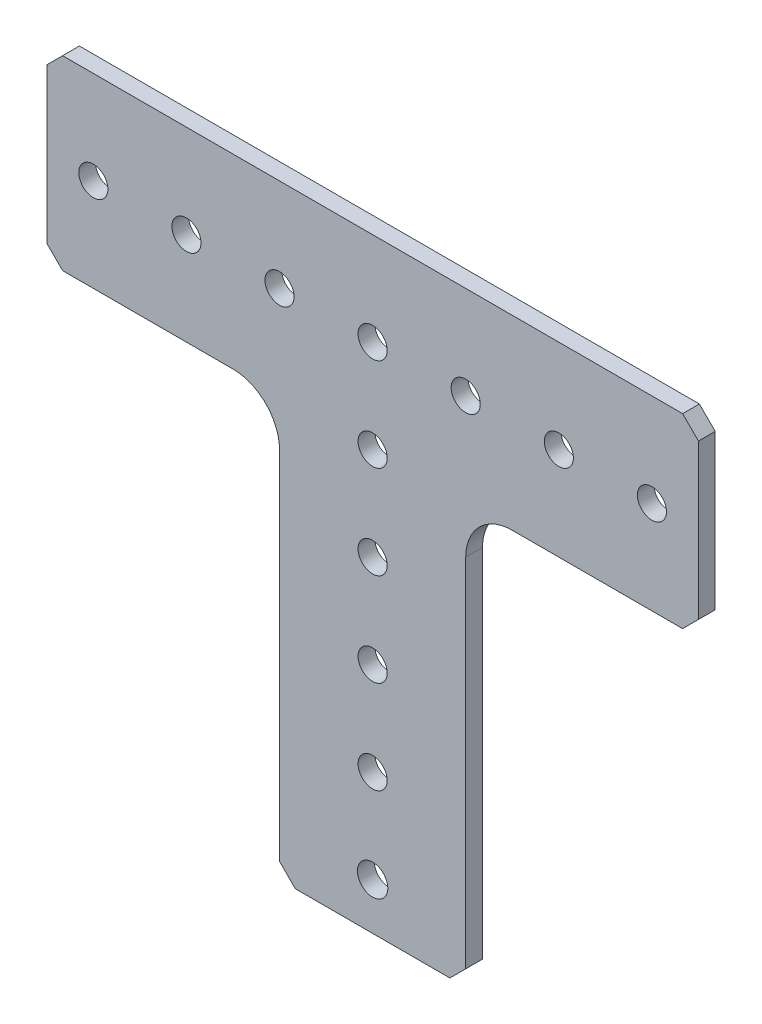
from build123d import *

# Parameters (mm, degrees)
SKETCH1_R                       = 2.0701
BOSS_EXTRUDE1_DEPTH             = 2.286
F_5_32_0_15625_DIAMETER_HOLE1_D = 3.96875


with BuildPart() as part:
    # Sketch1 → Boss-Extrude1 (new body)
    with BuildSketch(Plane.XY.offset(2.286)):
        with BuildLine():
            Line((12.7, -54.991), (12.7, -6.35))
            ThreePointArc((12.7, -6.35), (14.559871939, -1.859871939), (19.05, 0))
            Line((19.05, 0), (42.291, 0))
            Line((42.291, 0), (44.45, 2.159))
            Line((44.45, 2.159), (44.45, 23.241))
            Line((44.45, 23.241), (42.291, 25.4))
            Line((42.291, 25.4), (-42.291, 25.4))
            Line((-42.291, 25.4), (-44.45, 23.241))
            Line((-44.45, 23.241), (-44.45, 2.159))
            Line((-44.45, 2.159), (-42.291, 0))
            Line((-42.291, 0), (-19.05, 0))
            ThreePointArc((-19.05, 0), (-14.559871939, -1.859871939), (-12.7, -6.35))
            Line((-12.7, -6.35), (-12.7, -54.991))
            Line((-12.7, -54.991), (-10.541, -57.15))
            Line((-10.541, -57.15), (10.541, -57.15))
            Line((10.541, -57.15), (12.7, -54.991))
        make_face()
        with Locations((0, -50.8)):
            Circle(SKETCH1_R, mode=Mode.SUBTRACT)
    extrude(amount=-BOSS_EXTRUDE1_DEPTH)

    # 5/32 (0.15625) Diameter Hole1 (through all)
    with Locations(Plane.XY.offset(2.286)):
        with Locations((-38.1, 12.7), (-25.4, 12.7), (-12.7, 12.7), (0, 12.7), (12.7, 12.7), (25.4, 12.7), (38.1, 12.7), (0, 0), (0, -12.7), (0, -25.4), (0, -38.1), (0, -50.8)):
            Hole(F_5_32_0_15625_DIAMETER_HOLE1_D / 2)


solid = part.part
